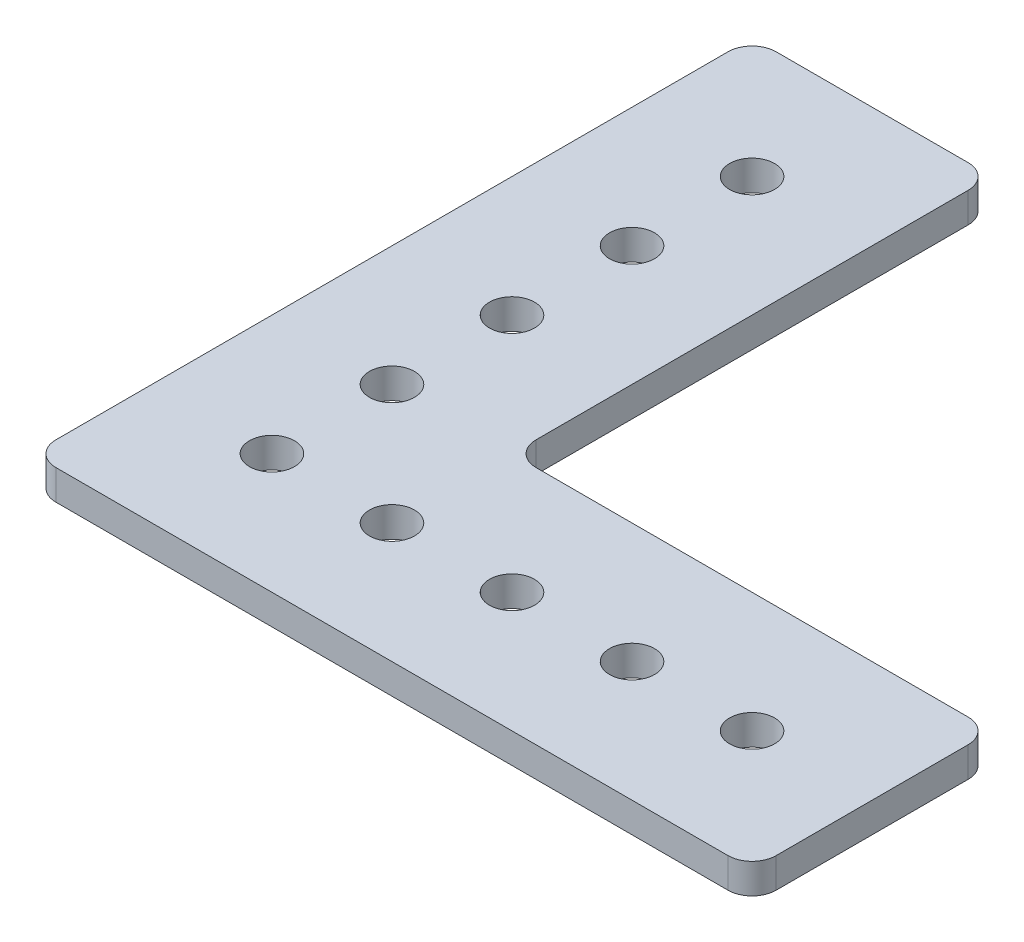
from build123d import *

# Parameters (mm, degrees)
SKETCH1_R           = 2.38125
BOSS_EXTRUDE1_DEPTH = 3.175


with BuildPart() as part:
    # Sketch1 → Boss-Extrude1 (new body)
    with BuildSketch(Plane(origin=(0, 0, 0), x_dir=(1, 0, 0), z_dir=(0, 1, 0))):
        with BuildLine():
            ThreePointArc((0, 2.54), (0.743948776, 0.743948776), (2.54, 0))
            Line((2.54, 0), (25.4, 0))
            Line((25.4, 0), (73.66, 0))
            ThreePointArc((73.66, 0), (75.456051224, 0.743948776), (76.2, 2.54))
            Line((76.2, 2.54), (76.2, 22.86))
            ThreePointArc((76.2, 22.86), (75.456051224, 24.656051224), (73.66, 25.4))
            Line((73.66, 25.4), (27.94, 25.4))
            ThreePointArc((27.94, 25.4), (26.143948776, 26.143948776), (25.4, 27.94))
            Line((25.4, 27.94), (25.4, 73.66))
            ThreePointArc((25.4, 73.66), (24.656051224, 75.456051224), (22.86, 76.2))
            Line((22.86, 76.2), (2.54, 76.2))
            ThreePointArc((2.54, 76.2), (0.743948776, 75.456051224), (0, 73.66))
            Line((0, 73.66), (0, 25.4))
            Line((0, 25.4), (0, 2.54))
        make_face()
        with Locations((12.7, 12.7)):
            Circle(SKETCH1_R, mode=Mode.SUBTRACT)
        with Locations((25.4, 12.7)):
            Circle(SKETCH1_R, mode=Mode.SUBTRACT)
        with Locations((38.1, 12.7)):
            Circle(SKETCH1_R, mode=Mode.SUBTRACT)
        with Locations((12.7, 25.4)):
            Circle(SKETCH1_R, mode=Mode.SUBTRACT)
        with Locations((12.7, 38.1)):
            Circle(SKETCH1_R, mode=Mode.SUBTRACT)
        with Locations((50.8, 12.7)):
            Circle(SKETCH1_R, mode=Mode.SUBTRACT)
        with Locations((63.5, 12.7)):
            Circle(SKETCH1_R, mode=Mode.SUBTRACT)
        with Locations((12.7, 50.8)):
            Circle(SKETCH1_R, mode=Mode.SUBTRACT)
        with Locations((12.7, 63.5)):
            Circle(SKETCH1_R, mode=Mode.SUBTRACT)
    extrude(amount=BOSS_EXTRUDE1_DEPTH)


solid = part.part
